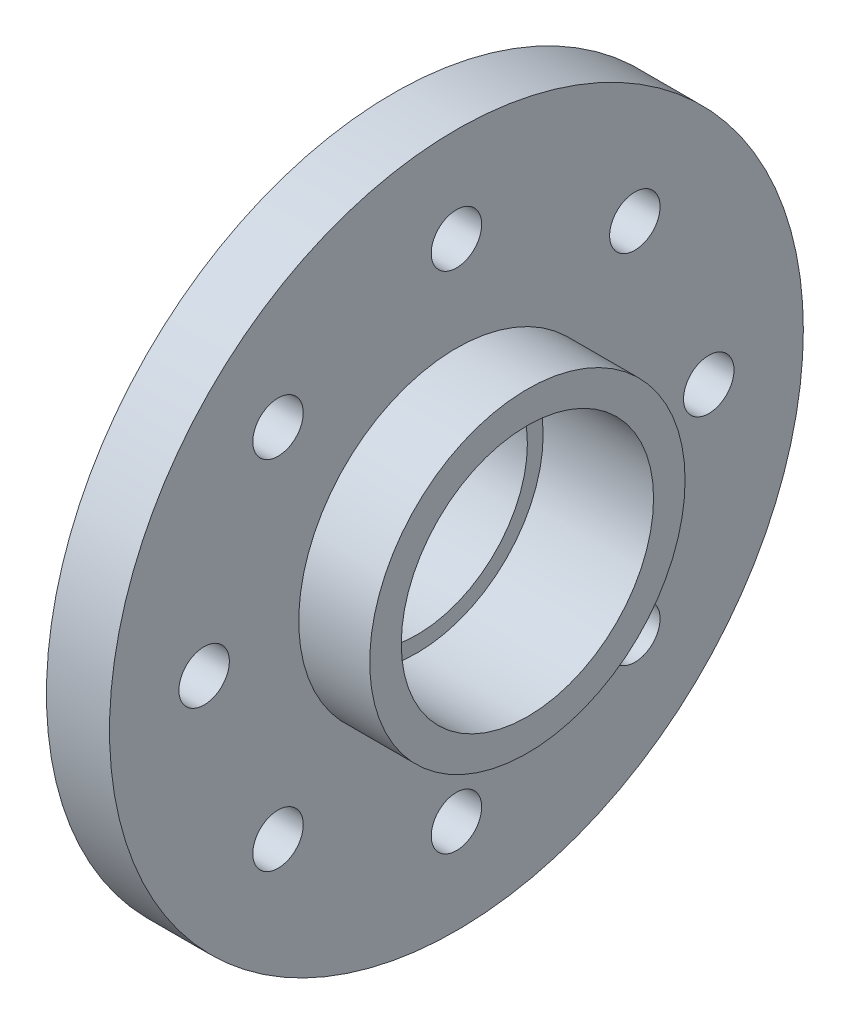
from build123d import *

# Parameters (mm, degrees)
SKETCH1_R                 = 5
SKETCH1_R_2               = 3.5
BOSS_EXTRUDE1_DEPTH       = 2
SKETCH2_R                 = 11
SKETCH2_R_2               = 4
BOSS_EXTRUDE2_DEPTH       = 1.25
BOSS_EXTRUDE3_START       = -0.75
SKETCH2_2_R               = 11
SKETCH2_2_R_2             = 4
BOSS_EXTRUDE3_DEPTH       = 0.75
SKETCH3_R                 = 5
SKETCH3_R_2               = 4
BOSS_EXTRUDE4_DEPTH       = 2.25
M2X0_4_TAPPED_HOLE1_D     = 1.6
M2X0_4_TAPPED_HOLE1_DEPTH = 5.2
M2X0_4_TAPPED_HOLE1_TIP   = 0.480688495


with BuildPart() as part:
    # Sketch1 → Boss-Extrude1 (new body)
    with BuildSketch(Plane(origin=(0, 0, 0), x_dir=(0, 0, -1), z_dir=(1, 0, 0))):
        Circle(SKETCH1_R)
        Circle(SKETCH1_R_2, mode=Mode.SUBTRACT)
    extrude(amount=BOSS_EXTRUDE1_DEPTH)

    # Sketch2 → Boss-Extrude2 (add)
    with BuildSketch(Plane(origin=(2, 0, 0), x_dir=(0, 0, -1), z_dir=(1, 0, 0))):
        Circle(SKETCH2_R)
        Circle(SKETCH2_R_2, mode=Mode.SUBTRACT)
    extrude(amount=BOSS_EXTRUDE2_DEPTH)

    # Sketch2_2 → Boss-Extrude3 (add)
    with BuildSketch(Plane(origin=(2, 0, 0), x_dir=(0, 0, -1), z_dir=(1, 0, 0)).offset(BOSS_EXTRUDE3_START)):
        Circle(SKETCH2_2_R)
        Circle(SKETCH2_2_R_2, mode=Mode.SUBTRACT)
    extrude(amount=BOSS_EXTRUDE3_DEPTH)

    # Sketch3 → Boss-Extrude4 (add)
    with BuildSketch(Plane(origin=(3.25, 0, 0), x_dir=(0, 0, -1), z_dir=(1, 0, 0))):
        Circle(SKETCH3_R)
        Circle(SKETCH3_R_2, mode=Mode.SUBTRACT)
    extrude(amount=BOSS_EXTRUDE4_DEPTH)

    # M2x0.4 Tapped Hole1
    with Locations(Plane(origin=(3.25, 0, 0), x_dir=(0, 0, -1), z_dir=(1, 0, 0))):
        with Locations((8, 0), (0, 8), (-5.656854249, 5.656854249), (5.656854249, 5.656854249), (5.656854249, -5.656854249), (0, -8), (-5.656854249, -5.656854249), (-8, 0)):
            Hole(M2X0_4_TAPPED_HOLE1_D / 2, depth=M2X0_4_TAPPED_HOLE1_DEPTH)
            with Locations((0, 0, -(M2X0_4_TAPPED_HOLE1_DEPTH + M2X0_4_TAPPED_HOLE1_TIP / 2))):  # 118° drill point
                Cone(0, M2X0_4_TAPPED_HOLE1_D / 2, M2X0_4_TAPPED_HOLE1_TIP, mode=Mode.SUBTRACT)


solid = part.part
